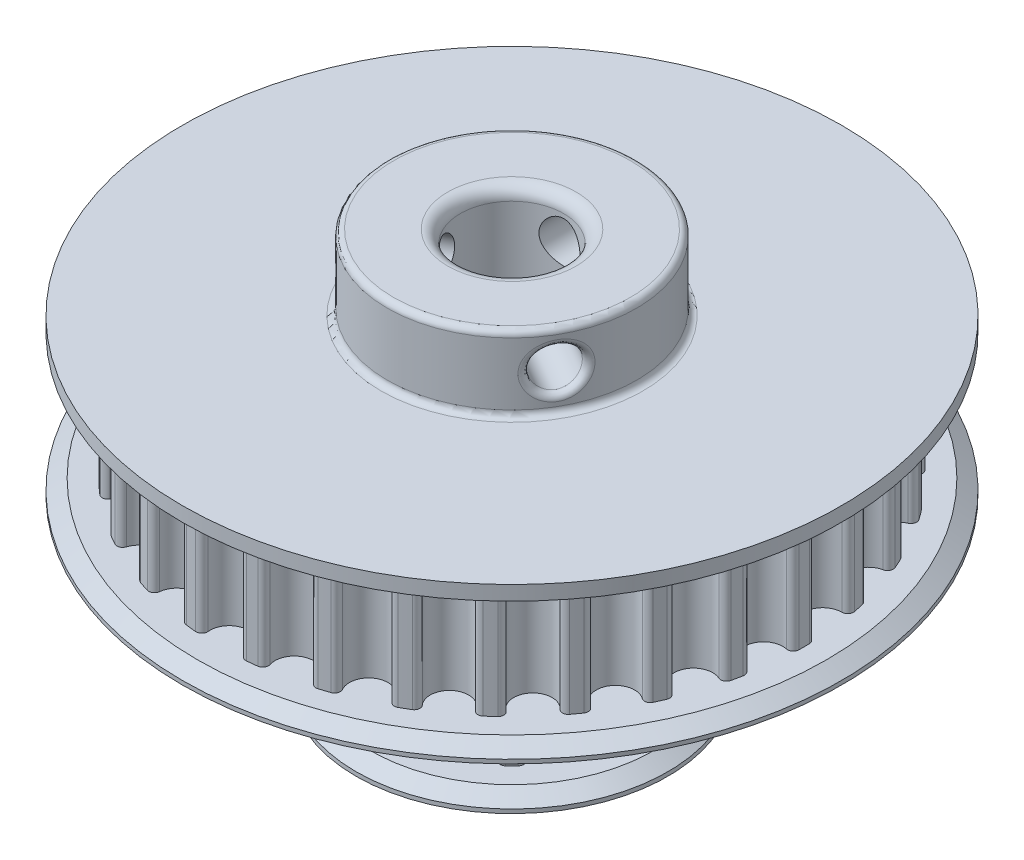
from build123d import *

# Parameters (mm, degrees)
BOSS_EXTRU_1_DEPTH           = 9.3
R_P_TITION_CIRCULAIRE1_COUNT = 30
ESQUISSE2_R                  = 26.4290252
BOSS_EXTRU_2_DEPTH           = 2
ESQUISSE4_R                  = 10
BOSS_EXTRU_3_DEPTH           = 6
ESQUISSE5_R                  = 1.65
ENL_V_MAT_EXTRU_2_DEPTH      = 27.4290252
R_P_TITION_CIRCULAIRE2_COUNT = 3
ESQUISSE10_R                 = 12.503417554
BOSS_EXTRU_6_DEPTH           = 2
BOSS_EXTRU_4_DEPTH           = 9.3
R_P_TITION_CIRCULAIRE3_COUNT = 12
ESQUISSE9_R                  = 12.503417554
BOSS_EXTRU_5_DEPTH           = 2
CHANFREIN1_SIZE              = 1.2
CHANFREIN1_SIZE2             = 0.840249046
CHANFREIN1_PART_2_SIZE       = 1.2
CHANFREIN1_PART_2_SIZE2      = 0.840249046
CHANFREIN1_PART_3_SIZE       = 1.2
CHANFREIN1_PART_3_SIZE2      = 0.840249046
CHANFREIN1_PART_4_SIZE       = 1.2
CHANFREIN1_PART_4_SIZE2      = 0.840249046
CHANFREIN1_PART_5_SIZE       = 1.2
CHANFREIN1_PART_5_SIZE2      = 0.840249046
CHANFREIN1_PART_6_SIZE       = 1.2
CHANFREIN1_PART_6_SIZE2      = 0.840249046
ESQUISSE3_R                  = 4.15
ENL_V_MAT_EXTRU_3_DEPTH      = 33.6
CONG_2_R                     = 0.5
CONG_3_R                     = 1


with BuildPart() as part:
    # Esquisse1 → Boss.-Extru.1 (new body)
    with BuildSketch(Plane(origin=(0, 0, 0), x_dir=(1, 0, 0), z_dir=(0, 1, 0))):
        with BuildLine():
            Line((0, 0), (-2.449, 23.300678548))
            ThreePointArc((-2.449, 23.300678548), (-2.23925905, 23.321769674), (-2.029336827, 23.340972856))
            ThreePointArc((-2.029336827, 23.340972856), (-1.662628217, 23.205334027), (-1.534260602, 22.83601729))
            ThreePointArc((-1.534260602, 22.83601729), (0, 21.1290252), (1.534260602, 22.83601729))
            ThreePointArc((1.534260602, 22.83601729), (1.662628217, 23.205334027), (2.029336827, 23.340972856))
            ThreePointArc((2.029336827, 23.340972856), (2.23925905, 23.321769674), (2.449, 23.300678548))
            Line((2.449, 23.300678548), (0, 0))
        make_face()
    boss_extru_1 = extrude(amount=BOSS_EXTRU_1_DEPTH)

    # Répétition circulaire1: Boss.-Extru.1 ×30 about axis
    r_p_tition_circulaire1_axis = Axis((0, 0, 0), (0, 1, 0))
    for i in range(1, R_P_TITION_CIRCULAIRE1_COUNT):
        add(boss_extru_1.rotate(r_p_tition_circulaire1_axis, i * 360 / R_P_TITION_CIRCULAIRE1_COUNT))

    # Esquisse2 → Boss.-Extru.2 (add)
    with BuildSketch(Plane(origin=(0, 9.3, 0), x_dir=(1, 0, 0), z_dir=(0, 1, 0))):
        Circle(ESQUISSE2_R)
    boss_extru_2 = extrude(amount=BOSS_EXTRU_2_DEPTH)

    # Symétrie1: Boss.-Extru.2 across plane
    add(boss_extru_2.mirror(Plane(origin=(0, 4.65, 0), x_dir=(0, 0, 1), z_dir=(0, -1, 0))))

    # Esquisse4 → Boss.-Extru.3 (add)
    with BuildSketch(Plane(origin=(0, 11.3, 0), x_dir=(1, 0, 0), z_dir=(0, 1, 0))):
        Circle(ESQUISSE4_R)
    extrude(amount=BOSS_EXTRU_3_DEPTH)

    # Esquisse5 → Enlèv. mat.-Extru.2 (cut, through all)
    with BuildSketch(Plane.XY):
        with Locations((0, 14.3)):
            Circle(ESQUISSE5_R)
    enl_v_mat_extru_2 = extrude(amount=-ENL_V_MAT_EXTRU_2_DEPTH, mode=Mode.SUBTRACT)

    # Répétition circulaire2: Enlèv. mat.-Extru.2 ×3 about axis
    r_p_tition_circulaire2_axis = Axis((0, 17.3, 0), (0, -1, 0))
    for i in range(1, R_P_TITION_CIRCULAIRE2_COUNT):
        add(enl_v_mat_extru_2.rotate(r_p_tition_circulaire2_axis, i * 360 / R_P_TITION_CIRCULAIRE2_COUNT), mode=Mode.SUBTRACT)

    # Esquisse10 → Boss.-Extru.6 (add)
    with BuildSketch(Plane.XZ.offset(2)):
        Circle(ESQUISSE10_R)
    extrude(amount=BOSS_EXTRU_6_DEPTH)

    # Esquisse7 → Boss.-Extru.4 (add)
    with BuildSketch(Plane(origin=(0, -4, 0), x_dir=(1, 0, 0), z_dir=(0, 1, 0))):
        with BuildLine():
            Line((0, 0), (-2.449, 9.139792428))
            ThreePointArc((-2.449, 9.139792428), (-2.275575871, 9.184506578), (-2.101336519, 9.225930384))
            ThreePointArc((-2.101336519, 9.225930384), (-1.70739936, 9.132025425), (-1.541940008, 8.762393406))
            ThreePointArc((-1.541940008, 8.762393406), (0, 7.162209394), (1.541940008, 8.762393406))
            ThreePointArc((1.541940008, 8.762393406), (1.70739936, 9.132025425), (2.101336519, 9.225930384))
            ThreePointArc((2.101336519, 9.225930384), (2.275575871, 9.184506578), (2.449, 9.139792428))
            Line((2.449, 9.139792428), (0, 0))
        make_face()
    boss_extru_4 = extrude(amount=-BOSS_EXTRU_4_DEPTH)

    # Répétition circulaire3: Boss.-Extru.4 ×12 about axis
    r_p_tition_circulaire3_axis = Axis((0, 0, 0), (0, 1, 0))
    for i in range(1, R_P_TITION_CIRCULAIRE3_COUNT):
        add(boss_extru_4.rotate(r_p_tition_circulaire3_axis, i * 360 / R_P_TITION_CIRCULAIRE3_COUNT))

    # Esquisse9 → Boss.-Extru.5 (add)
    with BuildSketch(Plane(origin=(0, -4, 0), x_dir=(1, 0, 0), z_dir=(0, 1, 0))):
        Circle(ESQUISSE9_R)
    boss_extru_5 = extrude(amount=BOSS_EXTRU_5_DEPTH)

    # Symétrie2: Boss.-Extru.5 across plane
    add(boss_extru_5.mirror(Plane.ZX.offset(-8.65)))

    # Chanfrein1
    chanfrein1_edges = [part.edges().sort_by_distance(p)[0] for p in [
        (-26.4290252, 9.3, 0),
    ]]
    chanfrein1_side = [part.faces().sort_by_distance(p)[0] for p in [
        (-25.681499482, 9.3, 0),
    ]]
    chamfer(chanfrein1_edges, length=CHANFREIN1_SIZE, length2=CHANFREIN1_SIZE2, reference=chanfrein1_side[0])

    # Chanfrein1 part 2
    chanfrein1_part_2_edges = [part.edges().sort_by_distance(p)[0] for p in [
        (-26.4290252, -2, 0),
    ]]
    chanfrein1_part_2_side = [part.faces().sort_by_distance(p)[0] for p in [
        (-25.681499482, -2, 0),
    ]]
    chamfer(chanfrein1_part_2_edges, length=CHANFREIN1_PART_2_SIZE, length2=CHANFREIN1_PART_2_SIZE2, reference=chanfrein1_part_2_side[0])

    # Chanfrein1 part 3
    chanfrein1_part_3_edges = [part.edges().sort_by_distance(p)[0] for p in [
        (-26.4290252, 0, 0),
    ]]
    chanfrein1_part_3_side = [part.faces().sort_by_distance(p)[0] for p in [
        (-25.681499482, 0, 0),
    ]]
    chamfer(chanfrein1_part_3_edges, length=CHANFREIN1_PART_3_SIZE, length2=CHANFREIN1_PART_3_SIZE2, reference=chanfrein1_part_3_side[0])

    # Chanfrein1 part 4
    chanfrein1_part_4_edges = [part.edges().sort_by_distance(p)[0] for p in [
        (-12.503417554, -4, 0),
    ]]
    chanfrein1_part_4_side = [part.faces().sort_by_distance(p)[0] for p in [
        (-12.1497675, -4, 0),
    ]]
    chamfer(chanfrein1_part_4_edges, length=CHANFREIN1_PART_4_SIZE, length2=CHANFREIN1_PART_4_SIZE2, reference=chanfrein1_part_4_side[0])

    # Chanfrein1 part 5
    chanfrein1_part_5_edges = [part.edges().sort_by_distance(p)[0] for p in [
        (-12.503417554, -15.3, 0),
    ]]
    chanfrein1_part_5_side = [part.faces().sort_by_distance(p)[0] for p in [
        (0, -15.3, 0),
    ]]
    chamfer(chanfrein1_part_5_edges, length=CHANFREIN1_PART_5_SIZE, length2=CHANFREIN1_PART_5_SIZE2, reference=chanfrein1_part_5_side[0])

    # Chanfrein1 part 6
    chanfrein1_part_6_edges = [part.edges().sort_by_distance(p)[0] for p in [
        (-12.503417554, -13.3, 0),
    ]]
    chanfrein1_part_6_side = [part.faces().sort_by_distance(p)[0] for p in [
        (-12.1497675, -13.3, 0),
    ]]
    chamfer(chanfrein1_part_6_edges, length=CHANFREIN1_PART_6_SIZE, length2=CHANFREIN1_PART_6_SIZE2, reference=chanfrein1_part_6_side[0])

    # Esquisse3 → Enlèv. mat.-Extru.3 (cut, through all)
    with BuildSketch(Plane(origin=(0, 17.3, 0), x_dir=(1, 0, 0), z_dir=(0, 1, 0))):
        Circle(ESQUISSE3_R)
    extrude(amount=-ENL_V_MAT_EXTRU_3_DEPTH, mode=Mode.SUBTRACT)

    # Congé2
    cong_2_edges = [part.edges().sort_by_distance(p)[0] for p in [
        (-10, 11.3, 0),
        (-10, 17.3, 0),
        (-1.650000023, 14.300000005, -9.862935666),
        (9.366552854, 14.300000005, 3.502525897),
        (-7.716552831, 14.300000005, 6.360409769),
    ]]
    fillet(cong_2_edges, radius=CONG_2_R)

    # Congé3
    cong_3_edges = [part.edges().sort_by_distance(p)[0] for p in [
        (-4.15, -15.3, 0),
        (-4.15, 17.3, 0),
    ]]
    fillet(cong_3_edges, radius=CONG_3_R)


solid = part.part
